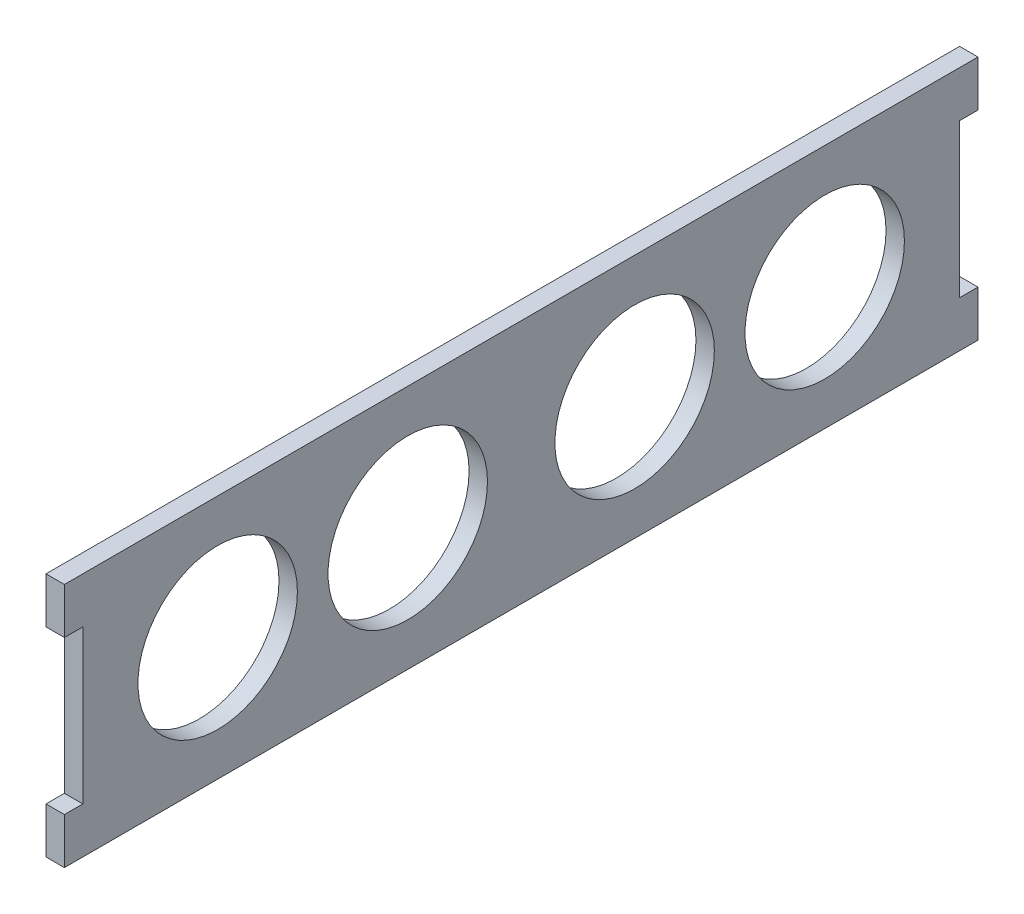
from build123d import *

# Parameters (mm, degrees)
SKETCH1_R           = 13
BOSS_EXTRUDE1_DEPTH = 3


with BuildPart() as part:
    # Sketch1 → Boss-Extrude1 (new body)
    with BuildSketch(Plane(origin=(0, 0, 0), x_dir=(0, 0, -1), z_dir=(1, 0, 0))):
        Polygon((74.5, 20), (-74.5, 20), (-74.5, 12.5), (-71.5, 12.5), (-71.5, -12.5), (-74.5, -12.5), (-74.5, -20), (74.5, -20), (74.5, -12.5), (71.5, -12.5), (71.5, 12.5), (74.5, 12.5), align=None)
        with Locations((-49.5, 0)):
            Circle(SKETCH1_R, mode=Mode.SUBTRACT)
        with Locations((-18.5, 0)):
            Circle(SKETCH1_R, mode=Mode.SUBTRACT)
        with Locations((18.5, 0)):
            Circle(SKETCH1_R, mode=Mode.SUBTRACT)
        with Locations((49.5, 0)):
            Circle(SKETCH1_R, mode=Mode.SUBTRACT)
    extrude(amount=BOSS_EXTRUDE1_DEPTH)


solid = part.part
